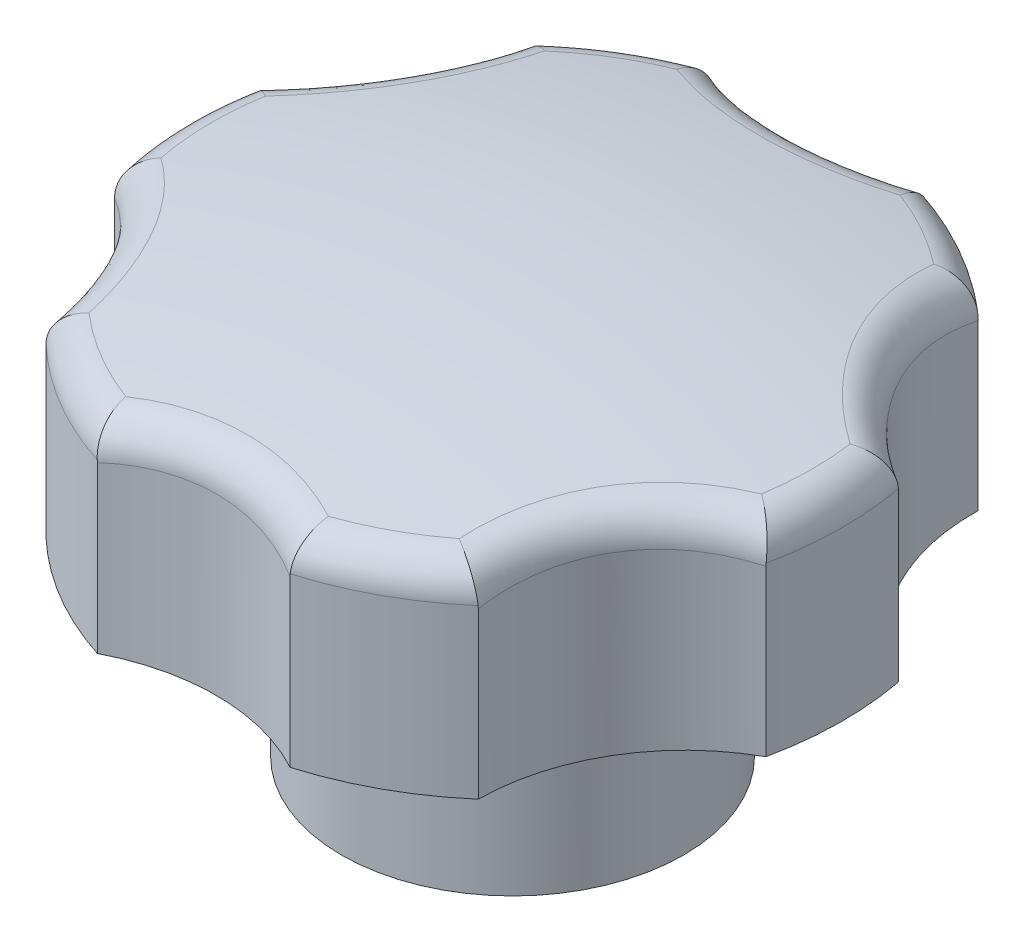
from build123d import *

# Parameters (mm, degrees)
SKETCH_1_R               = 27
EXTRUDE_1_DEPTH          = 19
SKETCH_2_R               = 17
CUT_EXTRUDE_1_DEPTH      = 20
PATTERN_CIRCULAR_1_COUNT = 6
SKETCH_4_R               = 14
EXTRUDE_2_DEPTH          = 16
HOLE_WIZARD_M1_1_D       = 10
HOLE_WIZARD_M1_1_DEPTH   = 20
HOLE_WIZARD_M1_1_TIP     = 3.004303095
SKETCH_9_R               = 1.5
CUT_EXTRUDE_2_DEPTH      = 28.0000001
CUT_EXTRUDE_2_DEPTH_BACK = 28.0000001
FILLET_1_R               = 3


with BuildPart() as part:
    # 스케치1 → 보스-돌출1 (new body)
    with BuildSketch(Plane(origin=(0, 0, 0), x_dir=(1, 0, 0), z_dir=(0, 1, 0))):
        Circle(SKETCH_1_R)
    extrude(amount=EXTRUDE_1_DEPTH)

    # 스케치2 → 컷-돌출1 (cut, through all)
    with BuildSketch(Plane(origin=(0, 19, 0), x_dir=(1, 0, 0), z_dir=(0, 1, 0))):
        with Locations((34.641016151, 20)):
            Circle(SKETCH_2_R)
    cut_extrude_1 = extrude(amount=-CUT_EXTRUDE_1_DEPTH, mode=Mode.SUBTRACT)

    # 원형 패턴1: 컷-돌출1 ×6 about axis
    pattern_circular_1_axis = Axis((-0.464151906, 0, 0.267978228), (0, 1, 0))
    for i in range(1, PATTERN_CIRCULAR_1_COUNT):
        add(cut_extrude_1.rotate(pattern_circular_1_axis, i * 360 / PATTERN_CIRCULAR_1_COUNT), mode=Mode.SUBTRACT)

    # 스케치3 → 컷-회전2 (revolve, cut)
    with BuildSketch(Plane.XY):
        with BuildLine():
            Line((0, 29), (27, 29))
            Line((27, 29), (27, 16.165246825))
            ThreePointArc((27, 16.165246825), (13.574201869, 18.289369415), (0, 19))
            Line((0, 19), (0, 29))
        make_face()
    revolve(axis=Axis((0, 19, 0), (0, -1, 0)), mode=Mode.SUBTRACT)

    # 스케치4 → 보스-돌출2 (add)
    with BuildSketch(Plane.XZ):
        Circle(SKETCH_4_R)
    extrude(amount=EXTRUDE_2_DEPTH)

    # M1 여유 구멍1
    with Locations(Plane(origin=(0, -16, 0), x_dir=(-1, 0, 0), z_dir=(0, -1, 0))):
        with Locations((0, 0)):
            Hole(HOLE_WIZARD_M1_1_D / 2, depth=HOLE_WIZARD_M1_1_DEPTH)
            with Locations((0, 0, -(HOLE_WIZARD_M1_1_DEPTH + HOLE_WIZARD_M1_1_TIP / 2))):  # 118° drill point
                Cone(0, HOLE_WIZARD_M1_1_D / 2, HOLE_WIZARD_M1_1_TIP, mode=Mode.SUBTRACT)

    # 스케치9 → 컷-돌출2 (cut, two sides)
    with BuildSketch(Plane(origin=(0, 0, 0), x_dir=(0, 0, -1), z_dir=(1, 0, 0))) as cut_extrude_2_sk:
        with Locations((0, -6)):
            Circle(SKETCH_9_R)
    extrude(amount=CUT_EXTRUDE_2_DEPTH, mode=Mode.SUBTRACT)
    extrude(cut_extrude_2_sk.sketch, amount=-CUT_EXTRUDE_2_DEPTH_BACK, mode=Mode.SUBTRACT)

    # 필렛1
    fillet_1_edges = [part.edges().sort_by_distance(p)[0] for p in [
        (-14, 0, 0),
        (20.017531602, 16.900260753, 11.866833107),
        (19.918584287, 16.949208673, -11.5),
        (-0.268213132, 16.900260753, -23.269107442),
        (-20.751157774, 16.801592363, -11.668009282),
        (-20.8468881, 16.751880647, 12.035956456),
        (-0.270786438, 16.801592363, 23.805034432),
        (13.2326505, 16.165246825, -23.535015631),
        (-14.041006051, 16.165246825, -23.06187653),
        (-26.99807334, 16.165246825, 0.322546041),
        (-13.778369735, 16.165246825, 23.219744345),
        (12.951667909, 16.165246825, 23.6908062),
        (26.849175808, 16.165246825, 2.849869895),
    ]]
    fillet(fillet_1_edges, radius=FILLET_1_R)


solid = part.part
